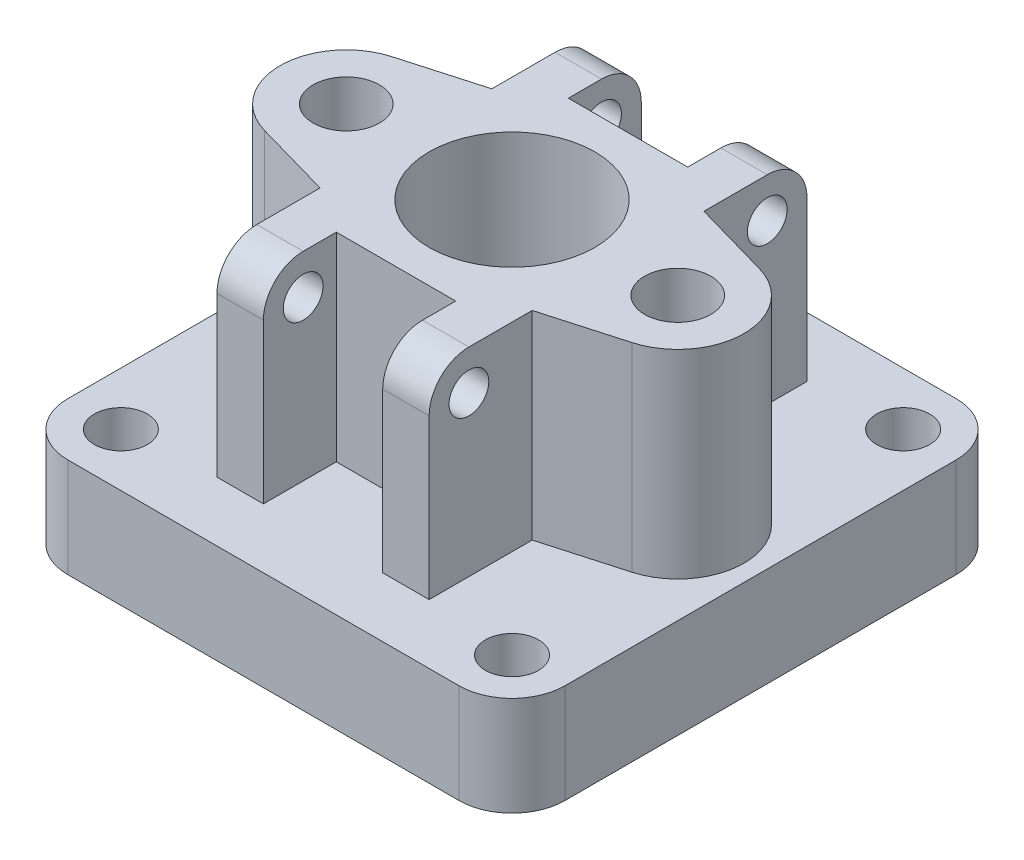
from build123d import *

# Parameters (mm, degrees)
CROQUIS1_W              = 75
CROQUIS1_H              = 75
SALIENTE_EXTRUIR1_DEPTH = 15
REDONDEO1_R             = 8
CROQUIS2_R              = 4
CORTAR_EXTRUIR1_DEPTH   = 15
SALIENTE_EXTRUIR2_DEPTH = 30
REDONDEO2_R             = 6
CROQUIS5_R              = 3
CORTAR_EXTRUIR2_DEPTH   = 54.5
CROQUIS6_R              = 5
CORTAR_EXTRUIR4_DEPTH   = 30
CROQUIS4_R              = 23
SALIENTE_EXTRUIR4_DEPTH = 5
CROQUIS8_R              = 12.5
CORTAR_EXTRUIR6_DEPTH   = 51


with BuildPart() as part:
    # Croquis1 → Saliente-Extruir1 (new body)
    with BuildSketch(Plane(origin=(0, 0, 0), x_dir=(1, 0, 0), z_dir=(0, 1, 0))):
        Rectangle(CROQUIS1_W, CROQUIS1_H)
    extrude(amount=SALIENTE_EXTRUIR1_DEPTH)

    # Redondeo1
    redondeo1_edges = [part.edges().sort_by_distance(p)[0] for p in [
        (37.5, 7.5, 37.5),
        (-37.5, 7.5, 37.5),
        (-37.5, 7.5, -37.5),
        (37.5, 7.5, -37.5),
    ]]
    fillet(redondeo1_edges, radius=REDONDEO1_R)

    # Croquis2 → Cortar-Extruir1 (cut)
    with BuildSketch(Plane(origin=(0, 15, 0), x_dir=(1, 0, 0), z_dir=(0, 1, 0))):
        with Locations((-29.5, 29.5)):
            Circle(CROQUIS2_R)
        with Locations((-29.5, -29.5)):
            Circle(CROQUIS2_R)
        with Locations((29.5, 29.5)):
            Circle(CROQUIS2_R)
        with Locations((29.5, -29.5)):
            Circle(CROQUIS2_R)
    extrude(amount=-CORTAR_EXTRUIR1_DEPTH, mode=Mode.SUBTRACT)

    # Croquis3 → Saliente-Extruir2 (add)
    with BuildSketch(Plane(origin=(0, 15, 0), x_dir=(1, 0, 0), z_dir=(0, 1, 0))):
        with BuildLine():
            Line((-16, -28.5), (-9, -28.5))
            Line((-9, -28.5), (-9, -17.5))
            Line((-9, -17.5), (9, -17.5))
            Line((9, -17.5), (9, -28.5))
            Line((9, -28.5), (16, -28.5))
            Line((16, -28.5), (16, -12.953381025))
            Line((16, -12.953381025), (27.733418669, -9.619169527))
            ThreePointArc((27.733418669, -9.619169527), (35, 0), (27.733418669, 9.619169527))
            Line((27.733418669, 9.619169527), (16, 12.953381025))
            Line((16, 12.953381025), (16, 28.5))
            Line((16, 28.5), (9, 28.5))
            Line((9, 28.5), (9, 17.5))
            Line((9, 17.5), (-9, 17.5))
            Line((-9, 17.5), (-9, 28.5))
            Line((-9, 28.5), (-16, 28.5))
            Line((-16, 28.5), (-16, 12.953381025))
            Line((-16, 12.953381025), (-27.733418669, 9.619169527))
            ThreePointArc((-27.733418669, 9.619169527), (-35, 0), (-27.733418669, -9.619169527))
            Line((-27.733418669, -9.619169527), (-16, -12.953381025))
            Line((-16, -12.953381025), (-16, -28.5))
        make_face()
    extrude(amount=SALIENTE_EXTRUIR2_DEPTH)

    # Redondeo2
    redondeo2_edges = [part.edges().sort_by_distance(p)[0] for p in [
        (-12.5, 45, 28.5),
        (12.5, 45, 28.5),
        (12.5, 45, -28.5),
        (-12.5, 45, -28.5),
    ]]
    fillet(redondeo2_edges, radius=REDONDEO2_R)

    # Croquis5 → Cortar-Extruir2 (cut, through all)
    with BuildSketch(Plane(origin=(16, 0, 0), x_dir=(0, 0, -1), z_dir=(1, 0, 0))):
        with Locations((-22.5, 39)):
            Circle(CROQUIS5_R)
        with Locations((22.5, 39)):
            Circle(CROQUIS5_R)
    extrude(amount=-CORTAR_EXTRUIR2_DEPTH, mode=Mode.SUBTRACT)

    # Croquis6 → Cortar-Extruir4 (cut)
    with BuildSketch(Plane(origin=(0, 45, 0), x_dir=(1, 0, 0), z_dir=(0, 1, 0))):
        with Locations((-25, 0)):
            Circle(CROQUIS6_R)
        with Locations((25, 0)):
            Circle(CROQUIS6_R)
    extrude(amount=-CORTAR_EXTRUIR4_DEPTH, mode=Mode.SUBTRACT)

    # Croquis4 → Saliente-Extruir4 (add)
    with BuildSketch(Plane(origin=(0, 0, 0), x_dir=(-1, 0, 0), z_dir=(0, -1, 0))):
        Circle(CROQUIS4_R)
    extrude(amount=SALIENTE_EXTRUIR4_DEPTH)

    # Croquis8 → Cortar-Extruir6 (cut, through all)
    with BuildSketch(Plane(origin=(0, 45, 0), x_dir=(1, 0, 0), z_dir=(0, 1, 0))):
        Circle(CROQUIS8_R)
    extrude(amount=-CORTAR_EXTRUIR6_DEPTH, mode=Mode.SUBTRACT)


solid = part.part
